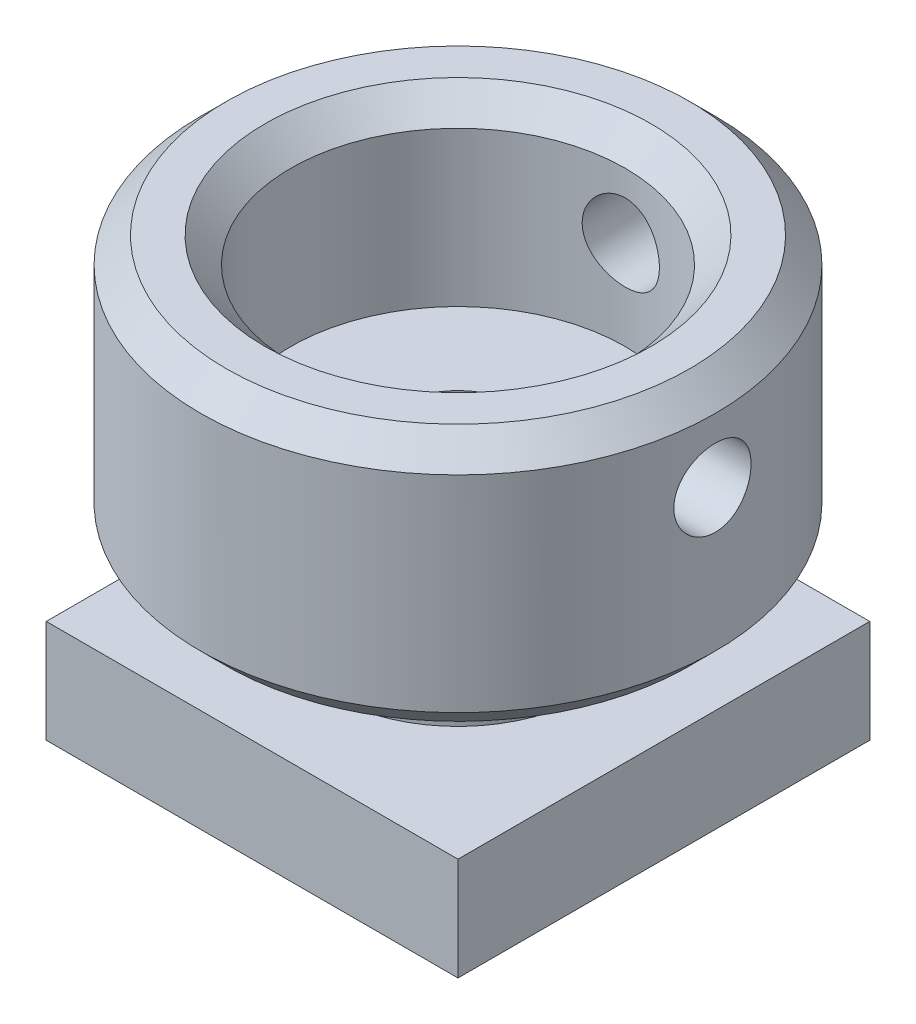
from build123d import *

# Parameters (mm, degrees)
F_3_0_3_DIAMETER_HOLE1_D               = 3
F_3_0_3_DIAMETER_HOLE1_DEPTH           = 12
F_3_0_3_DIAMETER_HOLE1_TIP             = 0.901290929
F_3_0_3_DIAMETER_HOLE1_ON_FACE_2_D     = 3
F_3_0_3_DIAMETER_HOLE1_ON_FACE_2_DEPTH = 12
F_3_0_3_DIAMETER_HOLE1_ON_FACE_2_TIP   = 0.901290929
CHAMFER1_SIZE                          = 1
CHAMFER2_SIZE                          = 1
SKETCH4_W                              = 16
SKETCH4_H                              = 16
SKETCH4_R                              = 5.091457849
EXTRUDE1_DEPTH                         = 4


with BuildPart() as part:
    # Sketch1 → Revolve1 (revolve)
    with BuildSketch(Plane.XY, mode=Mode.PRIVATE) as revolve1_sk:
        Polygon((2.5, 0), (2.5, 10), (6.5, 10), (6.5, 17), (10, 17), (10, 7), (5, 7), (5, 4), (8, 4), (8, 0), align=None)
    revolve(revolve1_sk.sketch.rotate(Axis((0, 0, 0), (0, 1, 0)), 90), axis=Axis((0, 0, 0), (0, 1, 0)))  # turned: the seam where the file's is

    # Ø3.0 (3) Diameter Hole1
    with Locations(Plane(origin=(0, 13.5, -10), x_dir=(-1, 0, 0), z_dir=(0, 0, -1))):
        with Locations((0, 0)):
            Hole(F_3_0_3_DIAMETER_HOLE1_D / 2, depth=F_3_0_3_DIAMETER_HOLE1_DEPTH)
            with Locations((0, 0, -(F_3_0_3_DIAMETER_HOLE1_DEPTH + F_3_0_3_DIAMETER_HOLE1_TIP / 2))):  # 118° drill point
                Cone(0, F_3_0_3_DIAMETER_HOLE1_D / 2, F_3_0_3_DIAMETER_HOLE1_TIP, mode=Mode.SUBTRACT)

    # Ø3.0 (3) Diameter Hole1 on face 2
    with Locations(Plane(origin=(10, 13.5, 0), x_dir=(0, 0, 1), z_dir=(1, 0, 0))):
        with Locations((0, 0)):
            Hole(F_3_0_3_DIAMETER_HOLE1_ON_FACE_2_D / 2, depth=F_3_0_3_DIAMETER_HOLE1_ON_FACE_2_DEPTH)
            with Locations((0, 0, -(F_3_0_3_DIAMETER_HOLE1_ON_FACE_2_DEPTH + F_3_0_3_DIAMETER_HOLE1_ON_FACE_2_TIP / 2))):  # 118° drill point
                Cone(0, F_3_0_3_DIAMETER_HOLE1_ON_FACE_2_D / 2, F_3_0_3_DIAMETER_HOLE1_ON_FACE_2_TIP, mode=Mode.SUBTRACT)

    # Chamfer1
    chamfer1_edges = [part.edges().sort_by_distance(p)[0] for p in [
        (0, 7, 10),
        (0, 17, 10),
    ]]
    chamfer(chamfer1_edges, length=CHAMFER1_SIZE)

    # Chamfer2
    chamfer2_edges = [part.edges().sort_by_distance(p)[0] for p in [
        (0, 17, 6.5),
    ]]
    chamfer(chamfer2_edges, length=CHAMFER2_SIZE)

    # Sketch4 → Extrude1 (add)
    with BuildSketch(Plane.XZ):
        Rectangle(SKETCH4_W, SKETCH4_H)
        Circle(SKETCH4_R, mode=Mode.SUBTRACT)
    extrude(amount=-EXTRUDE1_DEPTH)


solid = part.part
